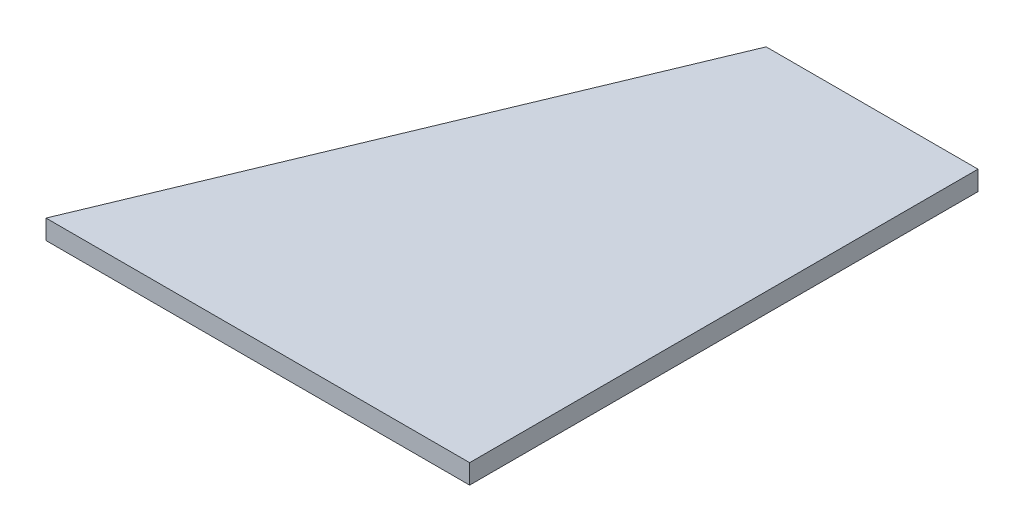
from build123d import *

# Parameters (mm, degrees)
SKETCH1_W           = 304.8
SKETCH1_H           = 76.2
BOSS_EXTRUDE1_DEPTH = 3.175
CUT_EXTRUDE3_DEPTH  = 0.254
CUT_EXTRUDE5_DEPTH  = 0.254
SKETCH3_3_OUTSIDE_W = 369.64
SKETCH3_3_OUTSIDE_H = 141.04
CUT_EXTRUDE9_DEPTH  = 315.196691105


with BuildPart() as part:
    # Sketch1 → Boss-Extrude1 (new body)
    with BuildSketch(Plane(origin=(0, 0, 0), x_dir=(1, 0, 0), z_dir=(0, 1, 0))):
        with Locations((-152.4, 38.1)):
            Rectangle(SKETCH1_W, SKETCH1_H)
    extrude(amount=BOSS_EXTRUDE1_DEPTH)

    # Sketch2 → Cut-Extrude3 (cut)
    with BuildSketch(Plane(origin=(0, 3.175, 0), x_dir=(1, 0, 0), z_dir=(0, 1, 0))):
        with BuildLine():
            Line((-304.8, 5.132354223), (-304.8, 0.390438323))
            add(Edge.make_bspline(
                [(-304.8, 0.390438323), (-303.821243343, 0.22923291), (-302.632591032, 0.100235841), (-301.136713645, 0)],
                knots=[0.767987957, 0.767987957, 0.767987957, 0.767987957, 1, 1, 1, 1], degree=3))
            Line((-301.136713645, 0), (-217.379871236, 0))
            add(Edge.make_bspline(
                [(-215.9, 0.210253502), (-216.602591478, 0.075926224), (-217.379871236, 0)],
                knots=[0.882956558, 0.882956558, 0.882956558, 1, 1, 1], degree=2))
            Line((-215.9, 0.210253502), (-215.9, 6.35))
            add(Edge.make_bspline(
                [(-304.8, 5.132354223), (-295.056068779, 7.913424716), (-284.63514545, 9.175759011), (-256.65451685, 7.910717471), (-231.983718042, 8.039058457), (-215.9, 6.35)],
                knots=[0.033341876, 0.033341876, 0.033341876, 0.033341876, 0.196819423, 0.285044024, 0.915587883, 0.915587883, 0.915587883, 0.915587883], degree=3))
        make_face()
        with BuildLine():
            Line((-304.748193138, 14.319973849), (-304.748193138, 9.578057948))
            add(Edge.make_bspline(
                [(-304.748193138, 9.578057948), (-303.76943648, 9.416852535), (-302.58078417, 9.287855466), (-301.084906782, 9.187619625)],
                knots=[0.767987957, 0.767987957, 0.767987957, 0.767987957, 1, 1, 1, 1], degree=3))
            Line((-301.084906782, 9.187619625), (-217.328064374, 9.187619625))
            add(Edge.make_bspline(
                [(-215.848193138, 9.397873128), (-216.550784616, 9.263545849), (-217.328064374, 9.187619625)],
                knots=[0.882956558, 0.882956558, 0.882956558, 1, 1, 1], degree=2))
            Line((-215.848193138, 9.397873128), (-215.848193138, 15.537619625))
            add(Edge.make_bspline(
                [(-304.748193138, 14.319973849), (-295.004261916, 17.101044341), (-284.583338588, 18.363378636), (-256.602709988, 17.098337097), (-231.93191118, 17.226678082), (-215.848193138, 15.537619625)],
                knots=[0.033341876, 0.033341876, 0.033341876, 0.033341876, 0.196819423, 0.285044024, 0.915587883, 0.915587883, 0.915587883, 0.915587883], degree=3))
        make_face()
        with BuildLine():
            Line((-304.77561062, 23.435546339), (-304.77561062, 18.693630439))
            add(Edge.make_bspline(
                [(-304.77561062, 18.693630439), (-303.796853962, 18.532425025), (-302.608201652, 18.403427957), (-301.112324264, 18.303192116)],
                knots=[0.767987957, 0.767987957, 0.767987957, 0.767987957, 1, 1, 1, 1], degree=3))
            Line((-301.112324264, 18.303192116), (-217.355481855, 18.303192116))
            add(Edge.make_bspline(
                [(-215.87561062, 18.513445618), (-216.578202097, 18.37911834), (-217.355481855, 18.303192116)],
                knots=[0.882956558, 0.882956558, 0.882956558, 1, 1, 1], degree=2))
            Line((-215.87561062, 18.513445618), (-215.87561062, 24.653192116))
            add(Edge.make_bspline(
                [(-304.77561062, 23.435546339), (-295.031679398, 26.216616832), (-284.61075607, 27.478951126), (-256.63012747, 26.213909587), (-231.959328661, 26.342250572), (-215.87561062, 24.653192116)],
                knots=[0.033341876, 0.033341876, 0.033341876, 0.033341876, 0.196819423, 0.285044024, 0.915587883, 0.915587883, 0.915587883, 0.915587883], degree=3))
        make_face()
        with BuildLine():
            Line((-304.723803757, 32.623165964), (-304.723803757, 27.881250064))
            add(Edge.make_bspline(
                [(-304.723803757, 27.881250064), (-303.7450471, 27.720044651), (-302.55639479, 27.591047582), (-301.060517402, 27.490811741)],
                knots=[0.767987957, 0.767987957, 0.767987957, 0.767987957, 1, 1, 1, 1], degree=3))
            Line((-301.060517402, 27.490811741), (-217.303674993, 27.490811741))
            add(Edge.make_bspline(
                [(-215.823803757, 27.701065244), (-216.526395235, 27.566737965), (-217.303674993, 27.490811741)],
                knots=[0.882956558, 0.882956558, 0.882956558, 1, 1, 1], degree=2))
            Line((-215.823803757, 27.701065244), (-215.823803757, 33.840811741))
            add(Edge.make_bspline(
                [(-304.723803757, 32.623165964), (-294.979872536, 35.404236457), (-284.558949208, 36.666570752), (-256.578320608, 35.401529213), (-231.907521799, 35.529870198), (-215.823803757, 33.840811741)],
                knots=[0.033341876, 0.033341876, 0.033341876, 0.033341876, 0.196819423, 0.285044024, 0.915587883, 0.915587883, 0.915587883, 0.915587883], degree=3))
        make_face()
        with BuildLine():
            Line((-304.692120731, 41.752034592), (-304.692120731, 37.010118692))
            add(Edge.make_bspline(
                [(-304.692120731, 37.010118692), (-303.713364073, 36.848913278), (-302.524711763, 36.71991621), (-301.028834375, 36.619680369)],
                knots=[0.767987957, 0.767987957, 0.767987957, 0.767987957, 1, 1, 1, 1], degree=3))
            Line((-301.028834375, 36.619680369), (-217.271991966, 36.619680369))
            add(Edge.make_bspline(
                [(-215.792120731, 36.829933871), (-216.494712209, 36.695606593), (-217.271991966, 36.619680369)],
                knots=[0.882956558, 0.882956558, 0.882956558, 1, 1, 1], degree=2))
            Line((-215.792120731, 36.829933871), (-215.792120731, 42.969680369))
            add(Edge.make_bspline(
                [(-304.692120731, 41.752034592), (-294.948189509, 44.533105085), (-284.527266181, 45.795439379), (-256.546637581, 44.53039784), (-231.875838773, 44.658738825), (-215.792120731, 42.969680369)],
                knots=[0.033341876, 0.033341876, 0.033341876, 0.033341876, 0.196819423, 0.285044024, 0.915587883, 0.915587883, 0.915587883, 0.915587883], degree=3))
        make_face()
        with BuildLine():
            Line((-304.640313869, 50.939654217), (-304.640313869, 46.197738317))
            add(Edge.make_bspline(
                [(-304.640313869, 46.197738317), (-303.661557211, 46.036532904), (-302.472904901, 45.907535835), (-300.977027513, 45.807299994)],
                knots=[0.767987957, 0.767987957, 0.767987957, 0.767987957, 1, 1, 1, 1], degree=3))
            Line((-300.977027513, 45.807299994), (-217.220185104, 45.807299994))
            add(Edge.make_bspline(
                [(-215.740313869, 46.017553497), (-216.442905346, 45.883226218), (-217.220185104, 45.807299994)],
                knots=[0.882956558, 0.882956558, 0.882956558, 1, 1, 1], degree=2))
            Line((-215.740313869, 46.017553497), (-215.740313869, 52.157299994))
            add(Edge.make_bspline(
                [(-304.640313869, 50.939654217), (-294.896382647, 53.72072471), (-284.475459319, 54.983059005), (-256.494830719, 53.718017466), (-231.82403191, 53.846358451), (-215.740313869, 52.157299994)],
                knots=[0.033341876, 0.033341876, 0.033341876, 0.033341876, 0.196819423, 0.285044024, 0.915587883, 0.915587883, 0.915587883, 0.915587883], degree=3))
        make_face()
        with BuildLine():
            Line((-304.66773135, 60.055226708), (-304.66773135, 55.313310807))
            add(Edge.make_bspline(
                [(-304.66773135, 55.313310807), (-303.688974693, 55.152105394), (-302.500322383, 55.023108326), (-301.004444995, 54.922872485)],
                knots=[0.767987957, 0.767987957, 0.767987957, 0.767987957, 1, 1, 1, 1], degree=3))
            Line((-301.004444995, 54.922872485), (-217.247602586, 54.922872485))
            add(Edge.make_bspline(
                [(-215.76773135, 55.133125987), (-216.470322828, 54.998798708), (-217.247602586, 54.922872485)],
                knots=[0.882956558, 0.882956558, 0.882956558, 1, 1, 1], degree=2))
            Line((-215.76773135, 55.133125987), (-215.76773135, 61.272872485))
            add(Edge.make_bspline(
                [(-304.66773135, 60.055226708), (-294.923800129, 62.836297201), (-284.502876801, 64.098631495), (-256.522248201, 62.833589956), (-231.851449392, 62.961930941), (-215.76773135, 61.272872485)],
                knots=[0.033341876, 0.033341876, 0.033341876, 0.033341876, 0.196819423, 0.285044024, 0.915587883, 0.915587883, 0.915587883, 0.915587883], degree=3))
        make_face()
        with BuildLine():
            Line((-304.615924488, 69.242846333), (-304.615924488, 64.500930433))
            add(Edge.make_bspline(
                [(-304.615924488, 64.500930433), (-303.637167831, 64.33972502), (-302.448515521, 64.210727951), (-300.952638133, 64.11049211)],
                knots=[0.767987957, 0.767987957, 0.767987957, 0.767987957, 1, 1, 1, 1], degree=3))
            Line((-300.952638133, 64.11049211), (-217.195795724, 64.11049211))
            add(Edge.make_bspline(
                [(-215.715924488, 64.320745612), (-216.418515966, 64.186418334), (-217.195795724, 64.11049211)],
                knots=[0.882956558, 0.882956558, 0.882956558, 1, 1, 1], degree=2))
            Line((-215.715924488, 64.320745612), (-215.715924488, 70.46049211))
            add(Edge.make_bspline(
                [(-304.615924488, 69.242846333), (-294.871993267, 72.023916826), (-284.451069938, 73.286251121), (-256.470441339, 72.021209581), (-231.79964253, 72.149550567), (-215.715924488, 70.46049211)],
                knots=[0.033341876, 0.033341876, 0.033341876, 0.033341876, 0.196819423, 0.285044024, 0.915587883, 0.915587883, 0.915587883, 0.915587883], degree=3))
        make_face()
        with BuildLine():
            Line((-215.183865707, 5.315478387), (-215.183865707, 0.573562486))
            add(Edge.make_bspline(
                [(-215.183865707, 0.573562486), (-214.20510905, 0.412357073), (-213.01645674, 0.283360005), (-211.520579352, 0.183124164)],
                knots=[0.767987957, 0.767987957, 0.767987957, 0.767987957, 1, 1, 1, 1], degree=3))
            Line((-211.520579352, 0.183124164), (-127.763736943, 0.183124164))
            add(Edge.make_bspline(
                [(-126.283865707, 0.393377666), (-126.986457185, 0.259050387), (-127.763736943, 0.183124164)],
                knots=[0.882956558, 0.882956558, 0.882956558, 1, 1, 1], degree=2))
            Line((-126.283865707, 0.393377666), (-126.283865707, 6.533124164))
            add(Edge.make_bspline(
                [(-215.183865707, 5.315478387), (-205.439934486, 8.09654888), (-195.019011157, 9.358883174), (-167.038382558, 8.093841635), (-142.367583749, 8.22218262), (-126.283865707, 6.533124164)],
                knots=[0.033341876, 0.033341876, 0.033341876, 0.033341876, 0.196819423, 0.285044024, 0.915587883, 0.915587883, 0.915587883, 0.915587883], degree=3))
        make_face()
        with BuildLine():
            Line((-215.132058845, 14.503098012), (-215.132058845, 9.761182112))
            add(Edge.make_bspline(
                [(-215.132058845, 9.761182112), (-214.153302188, 9.599976698), (-212.964649877, 9.47097963), (-211.46877249, 9.370743789)],
                knots=[0.767987957, 0.767987957, 0.767987957, 0.767987957, 1, 1, 1, 1], degree=3))
            Line((-211.46877249, 9.370743789), (-127.711930081, 9.370743789))
            add(Edge.make_bspline(
                [(-126.232058845, 9.580997291), (-126.934650323, 9.446670013), (-127.711930081, 9.370743789)],
                knots=[0.882956558, 0.882956558, 0.882956558, 1, 1, 1], degree=2))
            Line((-126.232058845, 9.580997291), (-126.232058845, 15.720743789))
            add(Edge.make_bspline(
                [(-215.132058845, 14.503098012), (-205.388127624, 17.284168505), (-194.967204295, 18.546502799), (-166.986575695, 17.28146126), (-142.315776887, 17.409802246), (-126.232058845, 15.720743789)],
                knots=[0.033341876, 0.033341876, 0.033341876, 0.033341876, 0.196819423, 0.285044024, 0.915587883, 0.915587883, 0.915587883, 0.915587883], degree=3))
        make_face()
        with BuildLine():
            Line((-215.159476327, 23.618670503), (-215.159476327, 18.876754602))
            add(Edge.make_bspline(
                [(-215.159476327, 18.876754602), (-214.180719669, 18.715549189), (-212.992067359, 18.58655212), (-211.496189971, 18.486316279)],
                knots=[0.767987957, 0.767987957, 0.767987957, 0.767987957, 1, 1, 1, 1], degree=3))
            Line((-211.496189971, 18.486316279), (-127.739347562, 18.486316279))
            add(Edge.make_bspline(
                [(-126.259476327, 18.696569782), (-126.962067804, 18.562242503), (-127.739347562, 18.486316279)],
                knots=[0.882956558, 0.882956558, 0.882956558, 1, 1, 1], degree=2))
            Line((-126.259476327, 18.696569782), (-126.259476327, 24.836316279))
            add(Edge.make_bspline(
                [(-215.159476327, 23.618670503), (-205.415545105, 26.399740996), (-194.994621777, 27.66207529), (-167.013993177, 26.397033751), (-142.343194369, 26.525374736), (-126.259476327, 24.836316279)],
                knots=[0.033341876, 0.033341876, 0.033341876, 0.033341876, 0.196819423, 0.285044024, 0.915587883, 0.915587883, 0.915587883, 0.915587883], degree=3))
        make_face()
        with BuildLine():
            Line((-215.107669465, 32.806290128), (-215.107669465, 28.064374228))
            add(Edge.make_bspline(
                [(-215.107669465, 28.064374228), (-214.128912807, 27.903168814), (-212.940260497, 27.774171746), (-211.444383109, 27.673935905)],
                knots=[0.767987957, 0.767987957, 0.767987957, 0.767987957, 1, 1, 1, 1], degree=3))
            Line((-211.444383109, 27.673935905), (-127.6875407, 27.673935905))
            add(Edge.make_bspline(
                [(-126.207669465, 27.884189407), (-126.910260942, 27.749862129), (-127.6875407, 27.673935905)],
                knots=[0.882956558, 0.882956558, 0.882956558, 1, 1, 1], degree=2))
            Line((-126.207669465, 27.884189407), (-126.207669465, 34.023935905))
            add(Edge.make_bspline(
                [(-215.107669465, 32.806290128), (-205.363738243, 35.587360621), (-194.942814915, 36.849694915), (-166.962186315, 35.584653376), (-142.291387506, 35.712994361), (-126.207669465, 34.023935905)],
                knots=[0.033341876, 0.033341876, 0.033341876, 0.033341876, 0.196819423, 0.285044024, 0.915587883, 0.915587883, 0.915587883, 0.915587883], degree=3))
        make_face()
    extrude(amount=-CUT_EXTRUDE3_DEPTH, mode=Mode.SUBTRACT)

    # Sketch3 → Cut-Extrude5 (cut)
    with BuildSketch(Plane(origin=(0, 3.175, 0), x_dir=(1, 0, 0), z_dir=(0, 1, 0))):
        with BuildLine():
            Line((-124.773731724, 0), (-73.973731724, 0))
            Line((-73.973731724, 0), (-73.973731724, 5.715))
            add(Edge.make_bspline(
                [(-124.773731724, 5.588), (-99.390849234, 12.627627449), (-73.973731724, 5.715)],
                knots=[0, 0, 0, 1, 1, 1], degree=2))
            Line((-124.773731724, 5.588), (-124.773731724, 0))
        make_face()
        with BuildLine():
            Line((-124.666073477, 9.555243731), (-73.866073477, 9.555243731))
            Line((-73.866073477, 9.555243731), (-73.866073477, 15.270243731))
            add(Edge.make_bspline(
                [(-124.666073477, 15.143243731), (-99.282006864, 21.683704535), (-73.866073477, 15.270243731)],
                knots=[0, 0, 0, 1, 1, 1], degree=2))
            Line((-124.666073477, 15.143243731), (-124.666073477, 9.555243731))
        make_face()
        with BuildLine():
            Line((-124.604715686, 19.129476511), (-73.804715686, 19.129476511))
            Line((-73.804715686, 19.129476511), (-73.804715686, 24.844476511))
            add(Edge.make_bspline(
                [(-124.604715686, 24.717476511), (-99.220649073, 31.257937315), (-73.804715686, 24.844476511)],
                knots=[0, 0, 0, 1, 1, 1], degree=2))
            Line((-124.604715686, 24.717476511), (-124.604715686, 19.129476511))
        make_face()
        with BuildLine():
            Line((-124.495240807, 28.763265862), (-73.695240807, 28.763265862))
            Line((-73.695240807, 28.763265862), (-73.695240807, 34.478265862))
            add(Edge.make_bspline(
                [(-124.495240807, 34.351265862), (-99.111174194, 40.891726665), (-73.695240807, 34.478265862)],
                knots=[0, 0, 0, 1, 1, 1], degree=2))
            Line((-124.495240807, 34.351265862), (-124.495240807, 28.763265862))
        make_face()
        with BuildLine():
            Line((-124.385765928, 38.397055212), (-73.585765928, 38.397055212))
            Line((-73.585765928, 38.397055212), (-73.585765928, 44.112055212))
            add(Edge.make_bspline(
                [(-124.385765928, 43.985055212), (-99.001699315, 50.525516016), (-73.585765928, 44.112055212)],
                knots=[0, 0, 0, 1, 1, 1], degree=2))
            Line((-124.385765928, 43.985055212), (-124.385765928, 38.397055212))
        make_face()
        with BuildLine():
            Line((-124.166816171, 49.235068231), (-73.366816171, 49.235068231))
            Line((-73.366816171, 49.235068231), (-73.366816171, 54.950068231))
            add(Edge.make_bspline(
                [(-124.166816171, 54.823068231), (-98.782749557, 61.363529035), (-73.366816171, 54.950068231)],
                knots=[0, 0, 0, 1, 1, 1], degree=2))
            Line((-124.166816171, 54.823068231), (-124.166816171, 49.235068231))
        make_face()
        with BuildLine():
            Line((-124.138868232, 59.013713621), (-73.338868232, 59.013713621))
            Line((-73.338868232, 59.013713621), (-73.338868232, 64.728713621))
            add(Edge.make_bspline(
                [(-124.138868232, 64.601713621), (-98.754801619, 71.142174425), (-73.338868232, 64.728713621)],
                knots=[0, 0, 0, 1, 1, 1], degree=2))
            Line((-124.138868232, 64.601713621), (-124.138868232, 59.013713621))
        make_face()
        with BuildLine():
            Line((-213.669393762, 38.449060159), (-162.869393762, 38.449060159))
            Line((-162.869393762, 38.449060159), (-162.869393762, 44.164060159))
            add(Edge.make_bspline(
                [(-213.669393762, 44.037060159), (-188.285327148, 50.577520962), (-162.869393762, 44.164060159)],
                knots=[0, 0, 0, 1, 1, 1], degree=2))
            Line((-213.669393762, 44.037060159), (-213.669393762, 38.449060159))
        make_face()
        with BuildLine():
            Line((-213.513008565, 49.239638781), (-162.713008565, 49.239638781))
            Line((-162.713008565, 49.239638781), (-162.713008565, 54.954638781))
            add(Edge.make_bspline(
                [(-213.513008565, 54.827638781), (-188.128941951, 61.368099585), (-162.713008565, 54.954638781)],
                knots=[0, 0, 0, 1, 1, 1], degree=2))
            Line((-213.513008565, 54.827638781), (-213.513008565, 49.239638781))
        make_face()
        with BuildLine():
            Line((-213.20023817, 60.030217404), (-162.40023817, 60.030217404))
            Line((-162.40023817, 60.030217404), (-162.40023817, 65.745217404))
            add(Edge.make_bspline(
                [(-213.20023817, 65.618217404), (-187.816171556, 72.158678208), (-162.40023817, 65.745217404)],
                knots=[0, 0, 0, 1, 1, 1], degree=2))
            Line((-213.20023817, 65.618217404), (-213.20023817, 60.030217404))
        make_face()
        Polygon((0, 76.2), (-31.75, 76.2), (-63.5, 0), (0, 0), align=None)
    extrude(amount=-CUT_EXTRUDE5_DEPTH, mode=Mode.SUBTRACT)

    # Sketch3_3 outside → Cut-Extrude9 (cut, through all)
    with BuildSketch(Plane(origin=(0, 3.175, 0), x_dir=(1, 0, 0), z_dir=(0, 1, 0))):
        with Locations((-152.4, 38.1)):
            Rectangle(SKETCH3_3_OUTSIDE_W, SKETCH3_3_OUTSIDE_H)
        Polygon((0, 0), (0, 76.2), (-31.75, 76.2), (-63.5, 0), align=None, mode=Mode.SUBTRACT)
    extrude(amount=-CUT_EXTRUDE9_DEPTH, mode=Mode.SUBTRACT)


solid = part.part
